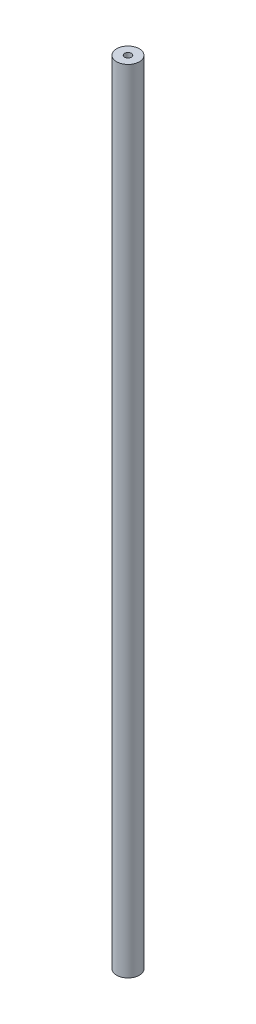
from build123d import *

# Parameters (mm, degrees)
SKETCH1_R           = 5
BOSS_EXTRUDE1_DEPTH = 350
SKETCH2_R           = 1.5
CUT_EXTRUDE1_DEPTH  = 10


with BuildPart() as part:
    # Sketch1 → Boss-Extrude1 (new body)
    with BuildSketch(Plane(origin=(0, 0, 0), x_dir=(1, 0, 0), z_dir=(0, 1, 0))):
        Circle(SKETCH1_R)
    extrude(amount=BOSS_EXTRUDE1_DEPTH)

    # Sketch2 → Cut-Extrude1 (cut)
    with BuildSketch(Plane(origin=(0, 350, 0), x_dir=(1, 0, 0), z_dir=(0, 1, 0))):
        Circle(SKETCH2_R)
    extrude(amount=-CUT_EXTRUDE1_DEPTH, mode=Mode.SUBTRACT)


solid = part.part
